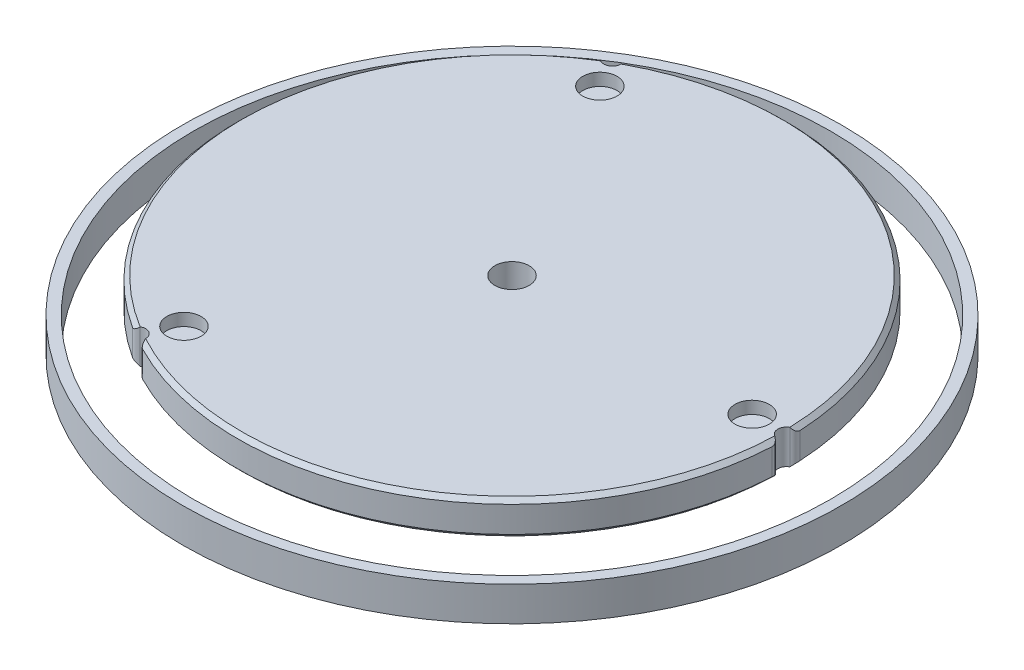
from build123d import *

# Parameters (mm, degrees)
SKETCH1_R               = 50.8
BOSS_EXTRUDE1_DEPTH     = 6.35
SKETCH2_R               = 3.175
CUT_EXTRUDE1_DEPTH      = 2.286
SKETCH3_R               = 3.175
CUT_EXTRUDE2_DEPTH      = 1
CUT_EXTRUDE2_DEPTH_BACK = 7.35
SKETCH4_R               = 1.5875
CUT_EXTRUDE3_DEPTH      = 7.35
CHAMFER1_SIZE           = 0.762
FILLET1_R               = 1.27
SKETCH5_R               = 61
SKETCH5_R_2             = 59
BOSS_EXTRUDE2_DEPTH     = 6.35


with BuildPart() as part:
    # Sketch1 → Boss-Extrude1 (new body)
    with BuildSketch(Plane(origin=(0, 0, 0), x_dir=(1, 0, 0), z_dir=(0, 1, 0))):
        Circle(SKETCH1_R)
    extrude(amount=BOSS_EXTRUDE1_DEPTH)

    # Sketch2 → Cut-Extrude1 (cut)
    with BuildSketch(Plane(origin=(0, 6.35, 0), x_dir=(1, 0, 0), z_dir=(0, 1, 0))):
        with Locations((-22.225, -38.494829198)):
            Circle(SKETCH2_R)
        with Locations((-22.225, 38.494829198)):
            Circle(SKETCH2_R)
        with Locations((44.45, 0)):
            Circle(SKETCH2_R)
    extrude(amount=-CUT_EXTRUDE1_DEPTH, mode=Mode.SUBTRACT)

    # Sketch3 → Cut-Extrude2 (cut, two sides)
    with BuildSketch(Plane(origin=(0, 6.35, 0), x_dir=(1, 0, 0), z_dir=(0, 1, 0))) as cut_extrude2_sk:
        Circle(SKETCH3_R)
    extrude(amount=CUT_EXTRUDE2_DEPTH, mode=Mode.SUBTRACT)
    extrude(cut_extrude2_sk.sketch, amount=-CUT_EXTRUDE2_DEPTH_BACK, mode=Mode.SUBTRACT)

    # Sketch4 → Cut-Extrude3 (cut, through all)
    with BuildSketch(Plane.XZ):
        with Locations((50.8, 0)):
            Circle(SKETCH4_R)
        with Locations((-25.4, 43.994090512)):
            Circle(SKETCH4_R)
        with Locations((-25.4, -43.994090512)):
            Circle(SKETCH4_R)
    extrude(amount=-CUT_EXTRUDE3_DEPTH, mode=Mode.SUBTRACT)

    # Chamfer1
    chamfer1_edges = [part.edges().sort_by_distance(p)[0] for p in [
        (25.4, 0, -43.994090512),
        (-50.8, 0, 0),
        (25.4, 0, 43.994090512),
        (25.4, 6.35, -43.994090512),
        (-50.8, 6.35, 0),
        (25.4, 6.35, 43.994090512),
    ]]
    chamfer(chamfer1_edges, length=CHAMFER1_SIZE)

    # Fillet1
    fillet1_edges = [part.edges().sort_by_distance(p)[0] for p in [
        (-24.012950162, 3.175, 44.766262124),
        (-26.76224515, 3.175, 43.178955922),
        (50.775195313, 3.175, -1.587306202),
        (50.775195313, 3.175, 1.587306202),
        (-24.012950162, 3.175, -44.766262124),
        (-26.76224515, 3.175, -43.178955922),
    ]]
    fillet(fillet1_edges, radius=FILLET1_R)


with BuildPart() as body_2:
    # Sketch5 → Boss-Extrude2 (new body)
    with BuildSketch(Plane.XZ):
        Circle(SKETCH5_R)
        Circle(SKETCH5_R_2, mode=Mode.SUBTRACT)
    extrude(amount=BOSS_EXTRUDE2_DEPTH)


solid = Compound([part.part, body_2.part])
